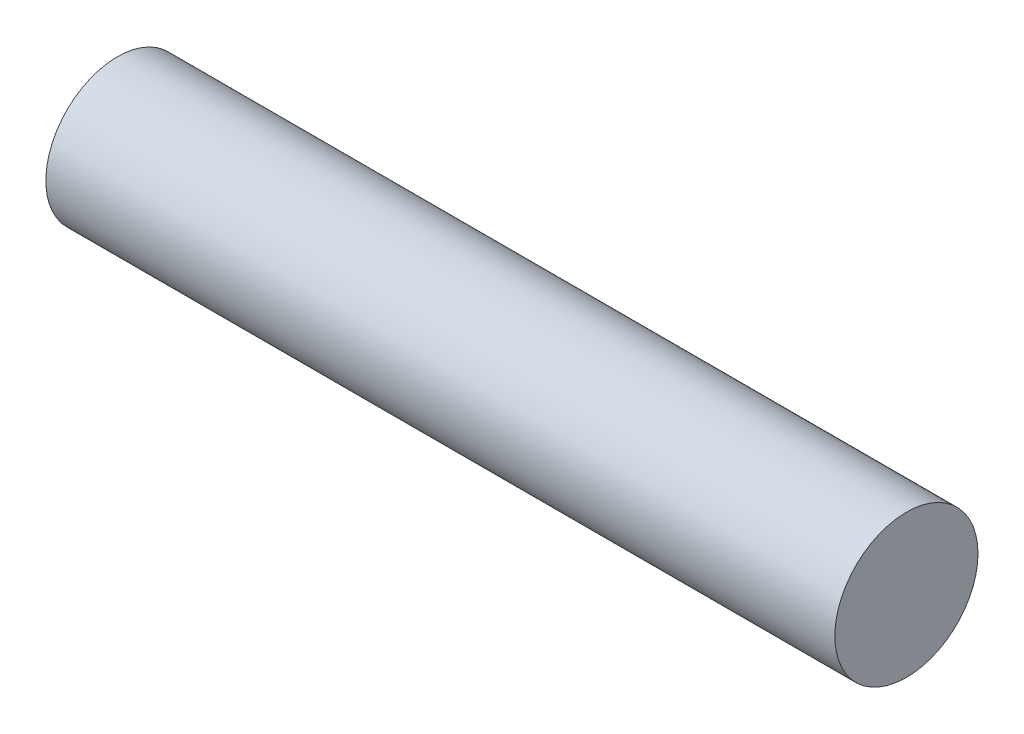
from build123d import *

# Parameters (mm, degrees)
ESQUISSE1_R        = 4.9
BOSS_EXTRU_1_DEPTH = 27


with BuildPart() as part:
    # Esquisse1 → Boss.-Extru.1 (new body, symmetric)
    with BuildSketch(Plane(origin=(0, 0, 0), x_dir=(0, 0, -1), z_dir=(1, 0, 0))):
        Circle(ESQUISSE1_R)
    extrude(amount=BOSS_EXTRU_1_DEPTH, both=True)


solid = part.part
